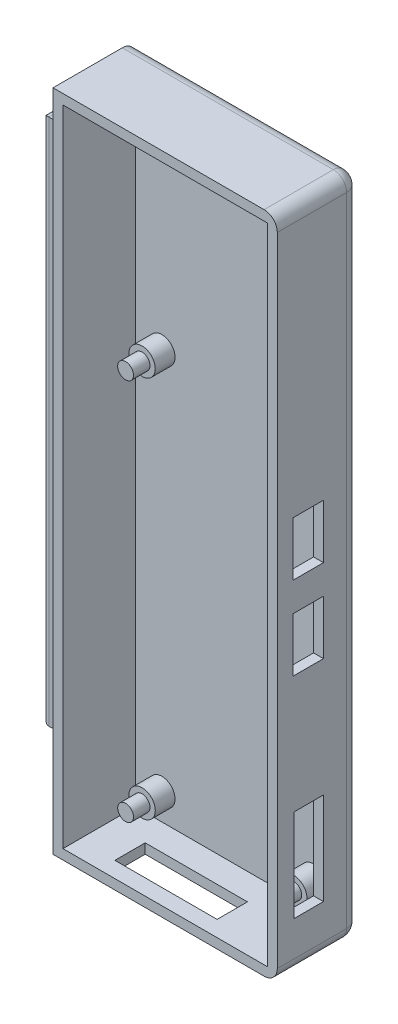
from build123d import *

# Parameters (mm, degrees)
ESQUISSE1_W             = 34
ESQUISSE1_H             = 100.65
BOSS_EXTRU_1_DEPTH      = 12.5
ESQUISSE2_W             = 31
ESQUISSE2_H             = 97.65
ENL_V_MAT_EXTRU_1_DEPTH = 11
ESQUISSE5_R             = 2
BOSS_EXTRU_4_DEPTH      = 3
ESQUISSE6_R             = 1.2
BOSS_EXTRU_5_DEPTH      = 5.5
CONG_2_R                = 2
CONG_3_R                = 2
CONG_4_R                = 2
ESQUISSE7_W             = 7.5
ESQUISSE7_H             = 80
BOSS_EXTRU_6_DEPTH      = 1
ESQUISSE9_W             = 9.45
ESQUISSE9_H             = 80
BOSS_EXTRU_7_DEPTH      = 1.7
ESQUISSE10_W            = 4.6
ESQUISSE10_H            = 8.2
ESQUISSE10_W_2          = 4.5
ESQUISSE10_H_2          = 14
ENL_V_MAT_EXTRU_2_DEPTH = 3
ESQUISSE11_W            = 15.5
ESQUISSE11_H            = 4.6
ENL_V_MAT_EXTRU_3_DEPTH = 3
CONG_7_R                = 1


with BuildPart() as part:
    # Esquisse1 → Boss.-Extru.1 (new body)
    with BuildSketch(Plane.XY):
        with Locations((17, 50.325)):
            Rectangle(ESQUISSE1_W, ESQUISSE1_H)
    extrude(amount=BOSS_EXTRU_1_DEPTH)

    # Esquisse2 → Enlèv. mat.-Extru.1 (cut)
    with BuildSketch(Plane.XY.offset(12.5)):
        with Locations((17, 50.325)):
            Rectangle(ESQUISSE2_W, ESQUISSE2_H)
    extrude(amount=-ENL_V_MAT_EXTRU_1_DEPTH, mode=Mode.SUBTRACT)

    # Esquisse5 → Boss.-Extru.4 (add)
    with BuildSketch(Plane.XY.offset(1.5)):
        with Locations((5.5, 63.5)):
            Circle(ESQUISSE5_R)
        with Locations((28.5, 63.5)):
            Circle(ESQUISSE5_R)
        with Locations((5.5, 5.5)):
            Circle(ESQUISSE5_R)
        with Locations((28.5, 5.5)):
            Circle(ESQUISSE5_R)
    extrude(amount=BOSS_EXTRU_4_DEPTH)

    # Esquisse6 → Boss.-Extru.5 (add)
    with BuildSketch(Plane.XY.offset(1.5)):
        with Locations((5.5, 63.5)):
            Circle(ESQUISSE6_R)
        with Locations((28.5, 63.5)):
            Circle(ESQUISSE6_R)
        with Locations((5.5, 5.5)):
            Circle(ESQUISSE6_R)
        with Locations((28.5, 5.5)):
            Circle(ESQUISSE6_R)
    extrude(amount=BOSS_EXTRU_5_DEPTH)

    # Congé2
    cong_2_edges = [part.edges().sort_by_distance(p)[0] for p in [
        (34, 0, 6.25),
    ]]
    fillet(cong_2_edges, radius=CONG_2_R)

    # Congé3
    cong_3_edges = [part.edges().sort_by_distance(p)[0] for p in [
        (34, 100.65, 6.25),
    ]]
    fillet(cong_3_edges, radius=CONG_3_R)

    # Congé4
    cong_4_edges = [part.edges().sort_by_distance(p)[0] for p in [
        (16, 0, 0),
        (34, 50.325, 0),
        (33.414213562, 0.585786438, 0),
        (16, 100.65, 0),
        (33.414213562, 100.064213562, 0),
    ]]
    fillet(cong_4_edges, radius=CONG_4_R)

    # Esquisse7 → Boss.-Extru.6 (add)
    with BuildSketch(Plane.ZY):
        with Locations((7, 55.45)):
            Rectangle(ESQUISSE7_W, ESQUISSE7_H)
    extrude(amount=BOSS_EXTRU_6_DEPTH)

    # Esquisse9 → Boss.-Extru.7 (add)
    with BuildSketch(Plane.ZY.offset(1)):
        with Locations((6.725, 55.45)):
            Rectangle(ESQUISSE9_W, ESQUISSE9_H)
    extrude(amount=BOSS_EXTRU_7_DEPTH)

    # Esquisse10 → Enlèv. mat.-Extru.2 (cut)
    with BuildSketch(Plane.ZY.offset(-32.5)):
        with Locations((7.8, 55.9)):
            Rectangle(ESQUISSE10_W, ESQUISSE10_H)
        with Locations((7.8, 43.3)):
            Rectangle(ESQUISSE10_W, ESQUISSE10_H)
        with Locations((7.75, 14.3)):
            Rectangle(ESQUISSE10_W_2, ESQUISSE10_H_2)
    extrude(amount=-ENL_V_MAT_EXTRU_2_DEPTH, mode=Mode.SUBTRACT)

    # Esquisse11 → Enlèv. mat.-Extru.3 (cut)
    with BuildSketch(Plane(origin=(0, 1.5, 0), x_dir=(1, 0, 0), z_dir=(0, 1, 0))):
        with Locations((14.724178104, -7.8)):
            Rectangle(ESQUISSE11_W, ESQUISSE11_H)
    extrude(amount=-ENL_V_MAT_EXTRU_3_DEPTH, mode=Mode.SUBTRACT)

    # Congé7
    cong_7_edges = [part.edges().sort_by_distance(p)[0] for p in [
        (-2.7, 55.45, 2),
        (-2.7, 15.45, 6.725),
        (-2.7, 55.45, 11.45),
        (-2.7, 95.45, 6.725),
    ]]
    fillet(cong_7_edges, radius=CONG_7_R)


solid = part.part
